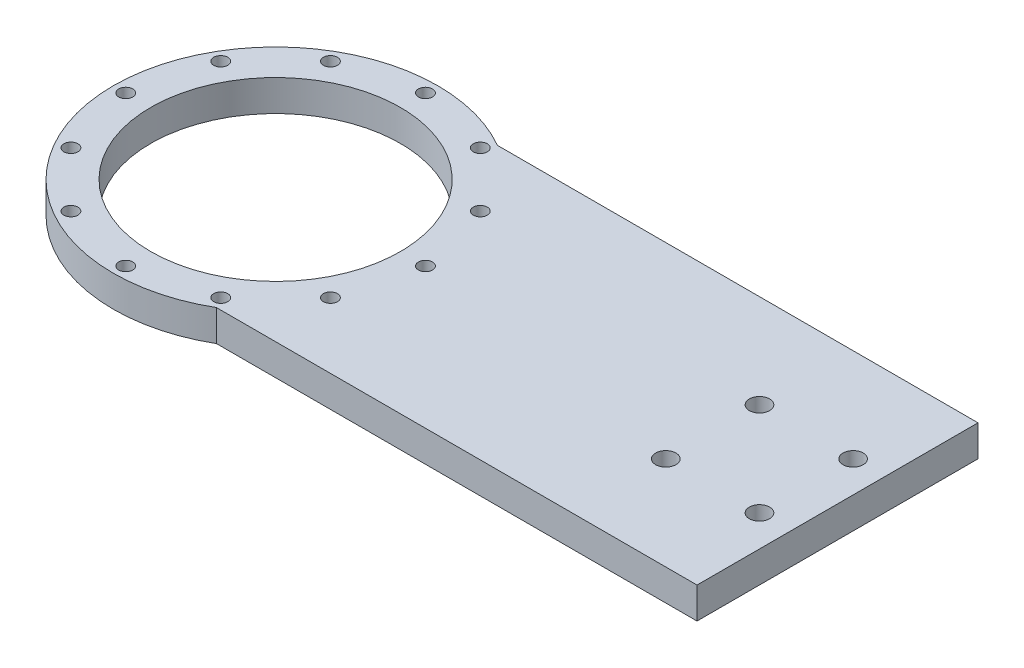
from build123d import *

# Parameters (mm, degrees)
SKETCH1_R            = 52
BOSS_EXTRUDE1_DEPTH  = 10
SKETCH2_W            = 180
SKETCH2_H            = 90
BOSS_EXTRUDE2_DEPTH  = 10
SKETCH3_R            = 40
CUT_EXTRUDE1_DEPTH   = 10
SKETCH4_R            = 2.25
CUT_EXTRUDE2_DEPTH   = 11
CIRPATTERN1_COUNT    = 12
SKETCH5_R            = 3.25
CUT_EXTRUDE3_DEPTH   = 11
LPATTERN1_COUNT      = 2
LPATTERN1_PITCH      = 30
LPATTERN1_COUNT_DIR2 = 2
LPATTERN1_PITCH_DIR2 = 30


with BuildPart() as part:
    # Sketch1 → Boss-Extrude1 (new body)
    with BuildSketch(Plane(origin=(0, 0, 0), x_dir=(1, 0, 0), z_dir=(0, 1, 0))):
        Circle(SKETCH1_R)
    extrude(amount=BOSS_EXTRUDE1_DEPTH)

    # Sketch2 → Boss-Extrude2 (add)
    with BuildSketch(Plane(origin=(0, 0, 0), x_dir=(1, 0, 0), z_dir=(0, 1, 0))):
        with Locations((90, 0)):
            Rectangle(SKETCH2_W, SKETCH2_H)
    extrude(amount=BOSS_EXTRUDE2_DEPTH)

    # Sketch3 → Cut-Extrude1 (cut)
    with BuildSketch(Plane(origin=(0, 10, 0), x_dir=(1, 0, 0), z_dir=(0, 1, 0))):
        Circle(SKETCH3_R)
    extrude(amount=-CUT_EXTRUDE1_DEPTH, mode=Mode.SUBTRACT)

    # Sketch4 → Cut-Extrude2 (cut, through all)
    with BuildSketch(Plane(origin=(0, 10, 0), x_dir=(1, 0, 0), z_dir=(0, 1, 0))):
        with Locations((0, 48)):
            Circle(SKETCH4_R)
    cut_extrude2 = extrude(amount=-CUT_EXTRUDE2_DEPTH, mode=Mode.SUBTRACT)

    # CirPattern1: Cut-Extrude2 ×12 about axis
    cirpattern1_axis = Axis((0, 0, 0), (0, 1, 0))
    for i in range(1, CIRPATTERN1_COUNT):
        add(cut_extrude2.rotate(cirpattern1_axis, i * 360 / CIRPATTERN1_COUNT), mode=Mode.SUBTRACT)

    # Sketch5 → Cut-Extrude3 (cut, through all)
    with BuildSketch(Plane(origin=(0, 10, 0), x_dir=(1, 0, 0), z_dir=(0, 1, 0))):
        with Locations((170, 15)):
            Circle(SKETCH5_R)
    cut_extrude3 = extrude(amount=-CUT_EXTRUDE3_DEPTH, mode=Mode.SUBTRACT)

    # LPattern1: Cut-Extrude3 2 × 2
    with Locations(*[(-i * LPATTERN1_PITCH, 0, j * LPATTERN1_PITCH_DIR2) for i in range(LPATTERN1_COUNT) for j in range(LPATTERN1_COUNT_DIR2) if (i, j) != (0, 0)]):
        add(cut_extrude3, mode=Mode.SUBTRACT)


solid = part.part
